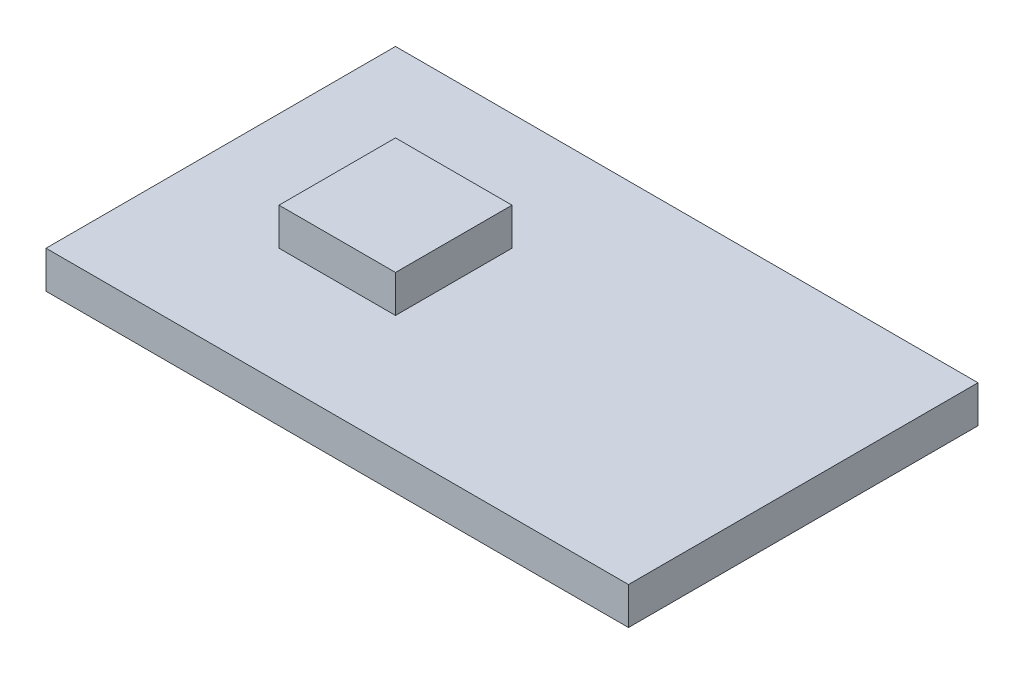
from build123d import *

# Parameters (mm, degrees)
SKETCH1_W      = 15.875
SKETCH1_H      = 9.525
EXTRUDE1_DEPTH = 1.016
SKETCH2_W      = 3.175
SKETCH2_H      = 3.175
EXTRUDE2_DEPTH = 1.016


with BuildPart() as part:
    # Sketch1 → Extrude1 (new body)
    with BuildSketch(Plane(origin=(0, 0, 0), x_dir=(1, 0, 0), z_dir=(0, 1, 0))):
        Rectangle(SKETCH1_W, SKETCH1_H)
    extrude(amount=EXTRUDE1_DEPTH)

    # Sketch2 → Extrude2 (add)
    with BuildSketch(Plane(origin=(0, 1.016, 0), x_dir=(-1, 0, 0), z_dir=(0, 1, 0))):
        with Locations((3.175, 0)):
            Rectangle(SKETCH2_W, SKETCH2_H)
    extrude(amount=EXTRUDE2_DEPTH)


solid = part.part
